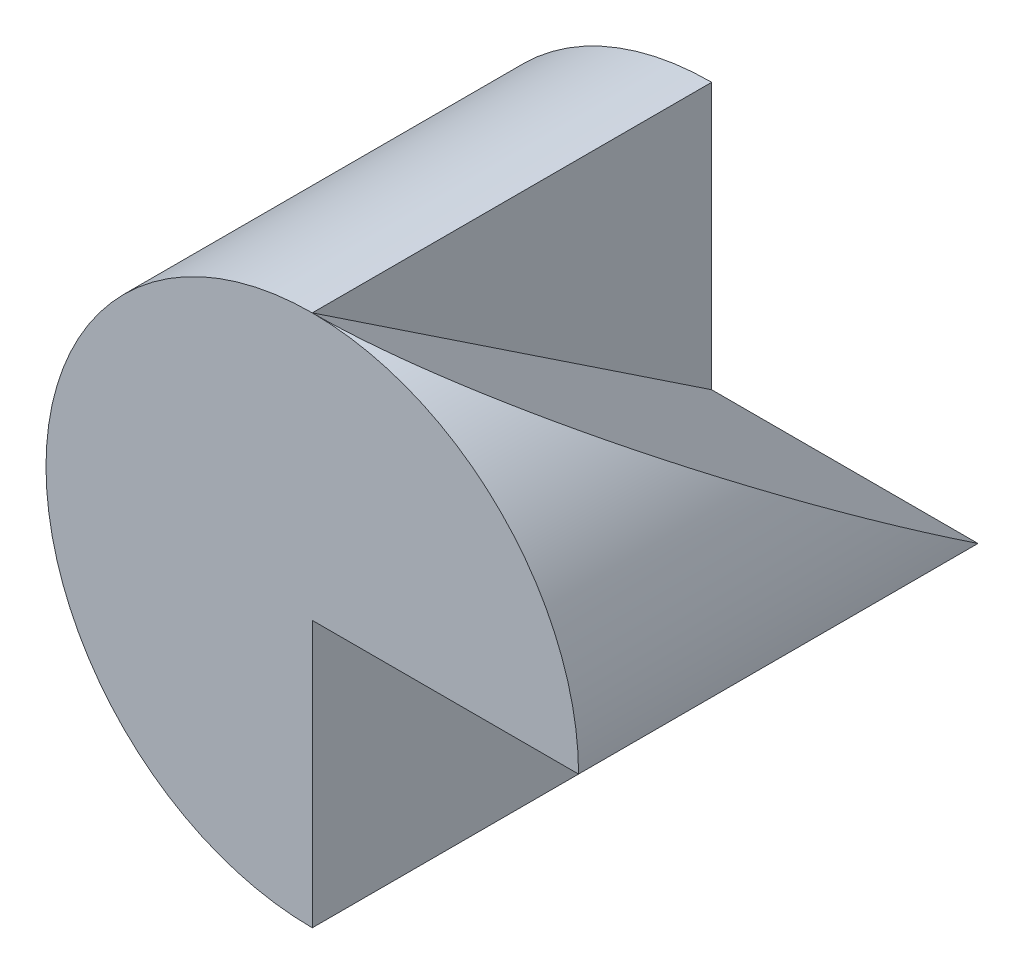
from build123d import *

# Parameters (mm, degrees)
SKETCH1_R           = 10
BOSS_EXTRUDE1_DEPTH = 15
CUT_EXTRUDE1_DEPTH  = 16
CUT_EXTRUDE2_DEPTH  = 10


with BuildPart() as part:
    # Sketch1 → Boss-Extrude1 (new body)
    with BuildSketch(Plane.XY):
        Circle(SKETCH1_R)
    extrude(amount=BOSS_EXTRUDE1_DEPTH)

    # Sketch2 → Cut-Extrude1 (cut, through all)
    with BuildSketch(Plane.XY.offset(15)):
        with BuildLine():
            Line((0, 0), (10, 0))
            ThreePointArc((10, 0), (7.071067812, -7.071067812), (0, -10))
            Line((0, -10), (0, 0))
        make_face()
    extrude(amount=-CUT_EXTRUDE1_DEPTH, mode=Mode.SUBTRACT)

    # Sketch5 → Cut-Extrude2 (cut)
    with BuildSketch(Plane(origin=(10, 0, 0), x_dir=(0, 0, -1), z_dir=(1, 0, 0))):
        Polygon((0, 0), (0, 10), (-15, 10), align=None)
    extrude(amount=-CUT_EXTRUDE2_DEPTH, mode=Mode.SUBTRACT)


solid = part.part
